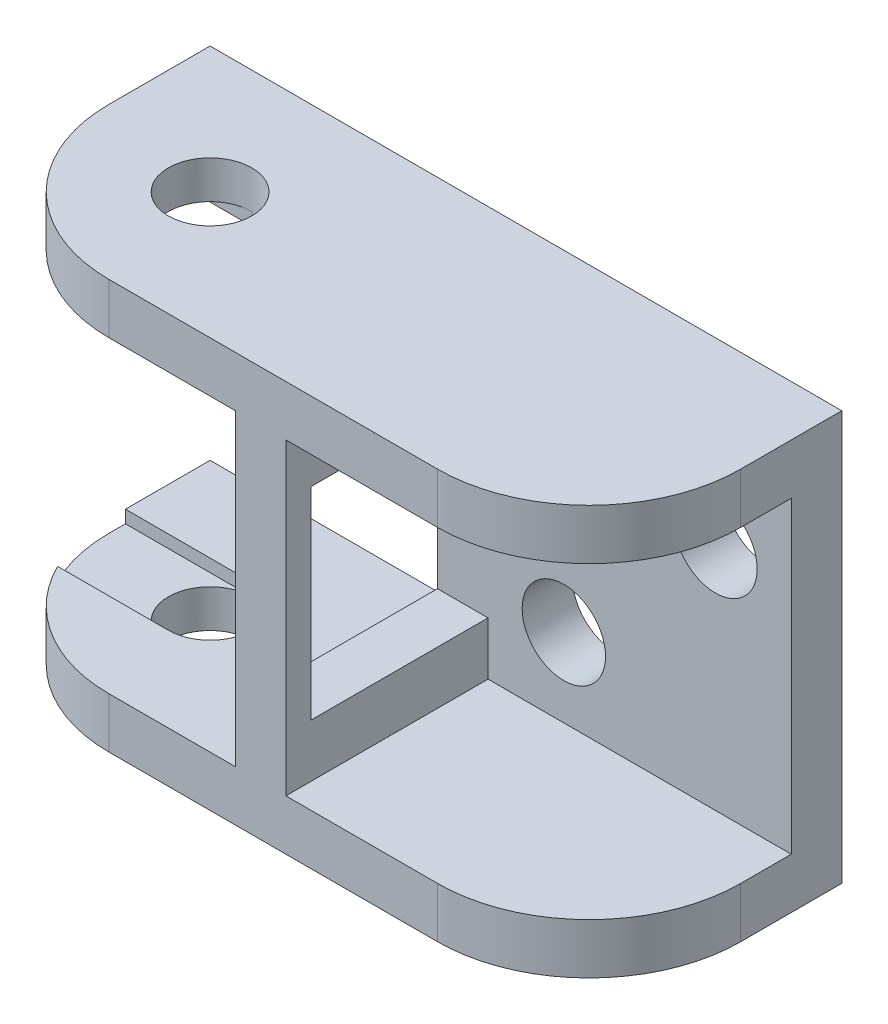
from build123d import *

# Parameters (mm, degrees)
EXTRUDE_2_DEPTH     = 10
SKETCH_3_R          = 1.5
EXTRUDE_3_DEPTH     = 1.5
SKETCH_5_R          = 1.65
CUT_EXTRUDE_2_DEPTH = 27.084669827
FILLET_1_R          = 6
SKETCH_6_W          = 10
SKETCH_6_H          = 1
SKETCH_6_W_2        = 5
EXTRUDE_4_DEPTH     = 4
SKETCH_7_W          = 5.689599517
SKETCH_7_H          = 3.3
CUT_EXTRUDE_3_DEPTH = 0.5
SKETCH_8_W          = 14.19653451
SKETCH_8_H          = 16.2
CUT_EXTRUDE_4_DEPTH = 30.624989451
MOVE_FACE_1_BY      = 12
CUT_EXTRUDE_5_REACH = 32.441
SKETCH_9_W          = 16.770919553
SKETCH_9_H          = 12.2
SKETCH_10_R         = 1.65
CUT_EXTRUDE_6_DEPTH = 31.127064245
FILLET_2_R          = 6
MOVE_FACE_2_BY      = 1


with BuildPart() as part:
    # Эскиз2 → Бобышка-Вытянуть2 (new body)
    with BuildSketch(Plane.XY):
        Polygon((0, 0), (0, 2), (13, 2), (13, -0.1), (24, -0.1), (24, -2.1), (11, -2.1), (11, 0), align=None)
    extrude(amount=EXTRUDE_2_DEPTH)

    # Эскиз3 → Бобышка-Вытянуть3 (add)
    with BuildSketch(Plane(origin=(0, -0.1, 0), x_dir=(1, 0, 0), z_dir=(0, 1, 0))):
        with Locations(Location((18.1, -5, 0), (0, 0, 90))):
            Circle(SKETCH_3_R)
    extrude(amount=EXTRUDE_3_DEPTH)

    # Эскиз5 → Вырез-Вытянуть2 (cut, through all)
    with BuildSketch(Plane.XZ):
        with Locations((5, 5)):
            Circle(SKETCH_5_R)
    extrude(amount=-CUT_EXTRUDE_2_DEPTH, mode=Mode.SUBTRACT)

    # Скругление1
    fillet_1_edges = [part.edges().sort_by_distance(p)[0] for p in [
        (24, -1.1, 10),
        (0, 1, 10),
    ]]
    fillet(fillet_1_edges, radius=FILLET_1_R)

    # Эскиз6 → Бобышка-Вытянуть4 (add)
    with BuildSketch(Plane(origin=(0, -2.1, 0), x_dir=(-1, 0, 0), z_dir=(0, -1, 0))):
        with Locations((-16, -0.5)):
            Rectangle(SKETCH_6_W, SKETCH_6_H)
        with Locations((-13.5, -9.5)):
            Rectangle(SKETCH_6_W_2, SKETCH_6_H)
    extrude(amount=EXTRUDE_4_DEPTH)

    # Эскиз7 → Вырез-Вытянуть3 (cut)
    with BuildSketch(Plane.XZ):
        with Locations((2.155200242, 5)):
            Rectangle(SKETCH_7_W, SKETCH_7_H)
    extrude(amount=-CUT_EXTRUDE_3_DEPTH, mode=Mode.SUBTRACT)

    # Зеркальное отражение1: part across plane


with BuildPart() as part_1:
    add(part.part)
    add(part.part.mirror(Plane.ZX.offset(-6.1)))

    # Эскиз8 → Вырез-Вытянуть4 (cut, through all)
    with BuildSketch(Plane.XY.offset(10)):
        with Locations((20.098267255, -6.1)):
            Rectangle(SKETCH_8_W, SKETCH_8_H)
    extrude(amount=-CUT_EXTRUDE_4_DEPTH, mode=Mode.SUBTRACT)

    # Move Face 1: a face moved outward by 12.0
    extrude(part_1.faces().sort_by_distance((13, -10.15, 5))[0], amount=MOVE_FACE_1_BY, dir=(1, 0, 0))

    # Вырез-Вытянуть5: up to this face of the body (flat: up to its plane)
    cut_extrude_5_end = Plane(part_1.part.faces().sort_by_distance((18, -6.1, 1))[0])
    # Эскиз9 → Вырез-Вытянуть5 (cut, up to the picked face)
    with BuildSketch(Plane.XY.offset(10), mode=Mode.PRIVATE) as cut_extrude_5_sk1:
        with Locations((21.385459776, -6.1)):
            Rectangle(SKETCH_9_W, SKETCH_9_H)
    cut_extrude_5_tool1 = split(extrude(cut_extrude_5_sk1.sketch, amount=-CUT_EXTRUDE_5_REACH, mode=Mode.PRIVATE), bisect_by=cut_extrude_5_end, keep=Keep.BOTH, mode=Mode.PRIVATE)
    add(cut_extrude_5_tool1.solids().sort_by(Axis((21.38546, -6.1, 10), (0, 0, -1)))[0], mode=Mode.SUBTRACT)

    # Эскиз10 → Вырез-Вытянуть6 (cut, through all)
    with BuildSketch(Plane.XY.offset(1)):
        with Locations((16, -9.1)):
            Circle(SKETCH_10_R)
        with Locations((22, -3.1)):
            Circle(SKETCH_10_R)
    extrude(amount=-CUT_EXTRUDE_6_DEPTH, mode=Mode.SUBTRACT)

    # Скругление2
    fillet_2_edges = [part_1.edges().sort_by_distance(p)[0] for p in [
        (25, -13.2, 10),
        (25, 1, 10),
    ]]
    fillet(fillet_2_edges, radius=FILLET_2_R)

    # Move Face 2: a face moved outward by 1.0
    extrude(part_1.faces().sort_by_distance((18.229149322, -6.1, 1))[0], amount=MOVE_FACE_2_BY, dir=(0, 0, 1))


solid = part_1.part
